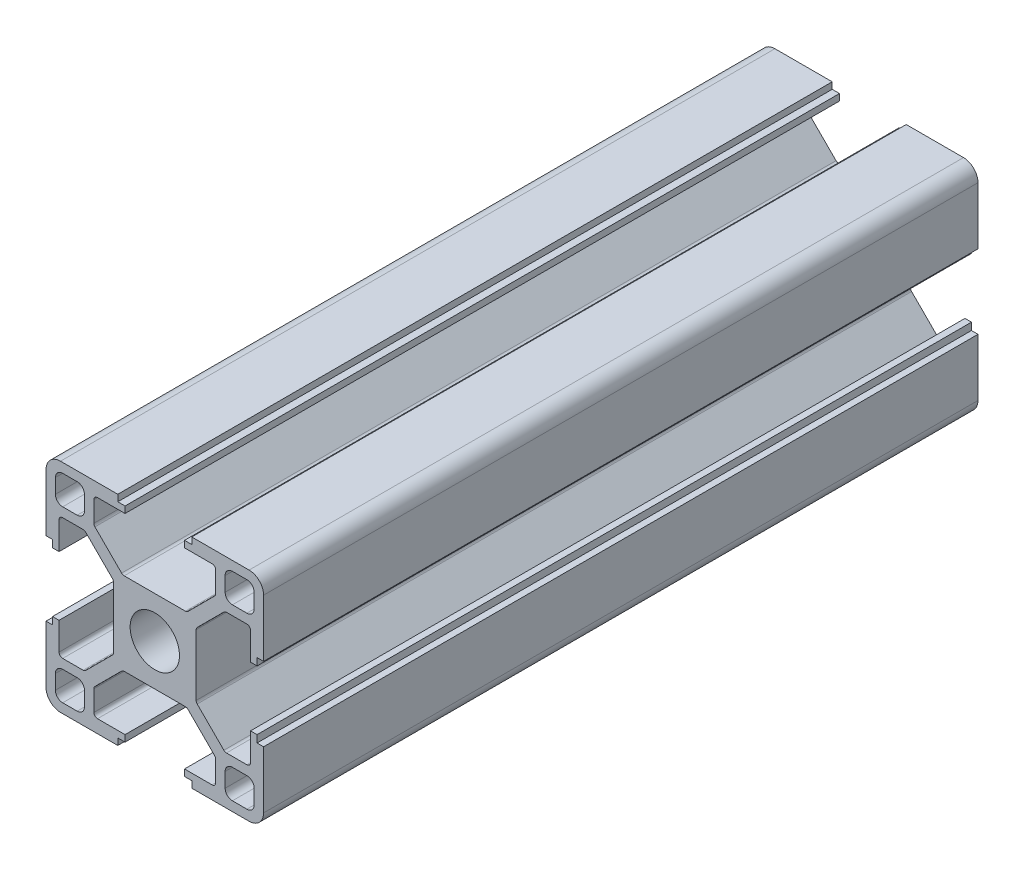
from build123d import *

# Parameters (mm, degrees)
SKETCH_1_W                       = 4
SKETCH_1_H                       = 4
EXTRUDE_1_DEPTH                  = 98.5
FILLET_1_R                       = 1
FILLET_2_R                       = 2
FILLET_3_R                       = 0.5
PATTERN_CIRCULAR_1_COUNT         = 4
FILLET_1_OF_PATTERN_CIRCULAR_1_R = 1
FILLET_2_OF_PATTERN_CIRCULAR_1_R = 2
FILLET_3_OF_PATTERN_CIRCULAR_1_R = 0.5
SKETCH_2_R                       = 3.4
CUT_EXTRUDE_1_DEPTH              = 99.5


with BuildPart() as part:
    # 草图1 → 凸台-拉伸1 (new body)
    with BuildSketch(Plane.XY):
        Polygon((5.7, 0), (5.7, 4.427207794), (9.672792206, 8.4), (13.2, 8.4), (13.2, 4.1), (14.1, 4.1), (14.1, 5.1), (15, 5.1), (15, 15), (5.1, 15), (5.1, 14.1), (4.1, 14.1), (4.1, 13.2), (8.4, 13.2), (8.4, 9.672792206), (4.427207794, 5.7), (0, 5.7), (0, 0), align=None)
        with Locations((11.7, 11.7)):
            Rectangle(SKETCH_1_W, SKETCH_1_H, mode=Mode.SUBTRACT)
    extrude_1 = extrude(amount=EXTRUDE_1_DEPTH)

    # 圆角1
    fillet_1_edges = [part.edges().sort_by_distance(p)[0] for p in [
        (13.7, 9.7, 49.25),
        (13.7, 13.7, 49.25),
        (9.7, 13.7, 49.25),
        (9.7, 9.7, 49.25),
    ]]
    fillet(fillet_1_edges, radius=FILLET_1_R)

    # 圆角2
    fillet_2_edges = [part.edges().sort_by_distance(p)[0] for p in [
        (15, 15, 49.25),
    ]]
    fillet(fillet_2_edges, radius=FILLET_2_R)

    # 圆角3
    fillet_3_edges = [part.edges().sort_by_distance(p)[0] for p in [
        (4.427207794, 5.7, 49.25),
        (8.4, 9.672792206, 49.25),
        (8.4, 13.2, 49.25),
        (13.2, 8.4, 49.25),
        (9.672792206, 8.4, 49.25),
        (5.7, 4.427207794, 49.25),
    ]]
    fillet(fillet_3_edges, radius=FILLET_3_R)

    # 阵列(圆周)1: 凸台-拉伸1 ×4 about axis
    pattern_circular_1_axis = Axis((0, 0, 0), (0, 0, 1))
    for i in range(1, PATTERN_CIRCULAR_1_COUNT):
        add(extrude_1.rotate(pattern_circular_1_axis, i * 360 / PATTERN_CIRCULAR_1_COUNT))

    # 圆角1 of 阵列(圆周)1
    fillet_1_of_pattern_circular_1_edges = [part.edges().sort_by_distance(p)[0] for p in [
        (-9.7, 13.7, 49.25),
        (-13.7, 13.7, 49.25),
        (-13.7, 9.7, 49.25),
        (-9.7, 9.7, 49.25),
        (-13.7, -9.7, 49.25),
        (-13.7, -13.7, 49.25),
        (-9.7, -13.7, 49.25),
        (-9.7, -9.7, 49.25),
        (9.7, -13.7, 49.25),
        (13.7, -13.7, 49.25),
        (13.7, -9.7, 49.25),
        (9.7, -9.7, 49.25),
    ]]
    fillet(fillet_1_of_pattern_circular_1_edges, radius=FILLET_1_OF_PATTERN_CIRCULAR_1_R)

    # 圆角2 of 阵列(圆周)1
    fillet_2_of_pattern_circular_1_edges = [part.edges().sort_by_distance(p)[0] for p in [
        (-15, 15, 49.25),
        (-15, -15, 49.25),
        (15, -15, 49.25),
    ]]
    fillet(fillet_2_of_pattern_circular_1_edges, radius=FILLET_2_OF_PATTERN_CIRCULAR_1_R)

    # 圆角3 of 阵列(圆周)1
    fillet_3_of_pattern_circular_1_edges = [part.edges().sort_by_distance(p)[0] for p in [
        (-5.7, 4.427207794, 49.25),
        (-9.672792206, 8.4, 49.25),
        (-13.2, 8.4, 49.25),
        (-8.4, 13.2, 49.25),
        (-8.4, 9.672792206, 49.25),
        (-4.427207794, 5.7, 49.25),
        (-4.427207794, -5.7, 49.25),
        (-8.4, -9.672792206, 49.25),
        (-8.4, -13.2, 49.25),
        (-13.2, -8.4, 49.25),
        (-9.672792206, -8.4, 49.25),
        (-5.7, -4.427207794, 49.25),
        (5.7, -4.427207794, 49.25),
        (9.672792206, -8.4, 49.25),
        (13.2, -8.4, 49.25),
        (8.4, -13.2, 49.25),
        (8.4, -9.672792206, 49.25),
        (4.427207794, -5.7, 49.25),
    ]]
    fillet(fillet_3_of_pattern_circular_1_edges, radius=FILLET_3_OF_PATTERN_CIRCULAR_1_R)

    # 草图2 → 切除-拉伸1 (cut, through all)
    with BuildSketch(Plane.XY.offset(98.5)):
        Circle(SKETCH_2_R)
    extrude(amount=-CUT_EXTRUDE_1_DEPTH, mode=Mode.SUBTRACT)


solid = part.part
